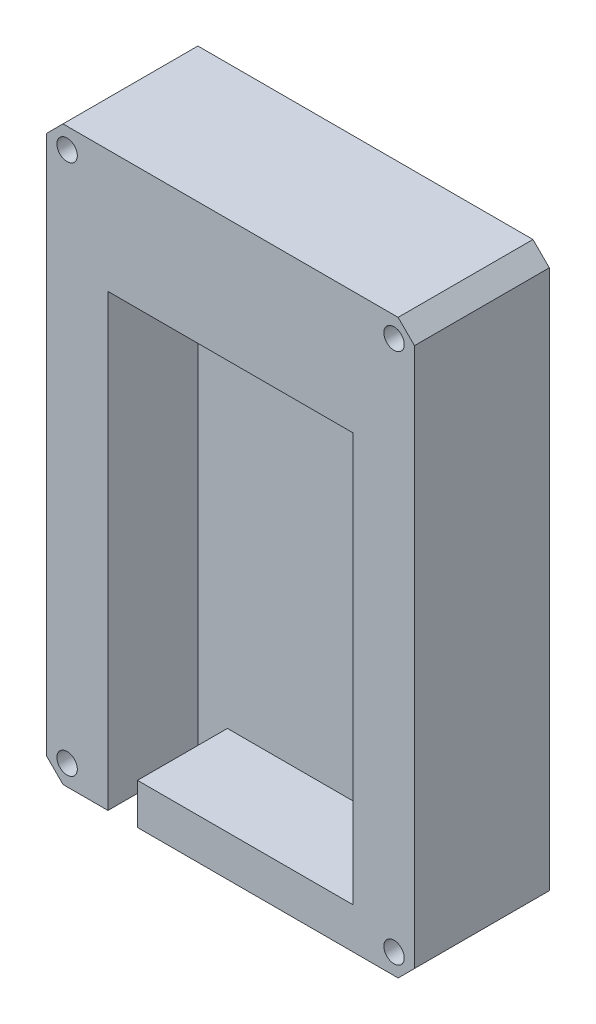
from build123d import *

# Parameters (mm, degrees)
BOSS_EXTRUDE1_DEPTH               = 11
SKETCH1_3_W                       = 45
SKETCH1_3_H                       = 70
BOSS_EXTRUDE2_DEPTH               = 5.5
TAP_DRILL_FOR_M3_TAP1_D           = 2.5
TAP_DRILL_FOR_M3_TAP1_CSINK_D     = 2.55
TAP_DRILL_FOR_M3_TAP1_CSINK_ANGLE = 90
CHAMFER1_SIZE                     = 2


with BuildPart() as part:
    # Sketch1 → Boss-Extrude1 (new body)
    with BuildSketch(Plane.XY):
        Polygon((-11.388490073, -35), (22.5, -35), (22.5, 35), (-22.5, 35), (-22.5, -35), (-15, -35), (-15, -30), (-15, 20), (15, 20), (15, -30), (-11.388490073, -30), align=None)
    extrude(amount=BOSS_EXTRUDE1_DEPTH)

    # Sketch1_3 → Boss-Extrude2 (add)
    with BuildSketch(Plane.XY):
        Rectangle(SKETCH1_3_W, SKETCH1_3_H)
    extrude(amount=-BOSS_EXTRUDE2_DEPTH)

    # Tap Drill for M3 Tap1 (through all)
    with Locations(Plane(origin=(0, 0, -5.5), x_dir=(-1, 0, 0), z_dir=(0, 0, -1))):
        with Locations((20, 32.5), (-20, 32.5), (-20, -32.5), (20, -32.5)):
            CounterSinkHole(TAP_DRILL_FOR_M3_TAP1_D / 2, TAP_DRILL_FOR_M3_TAP1_CSINK_D / 2, counter_sink_angle=TAP_DRILL_FOR_M3_TAP1_CSINK_ANGLE)

    # Chamfer1
    chamfer1_edges = [part.edges().sort_by_distance(p)[0] for p in [
        (22.5, -35, 2.75),
        (22.5, 35, 2.75),
        (-22.5, 35, 2.75),
        (-22.5, -35, 2.75),
    ]]
    chamfer(chamfer1_edges, length=CHAMFER1_SIZE)


solid = part.part
